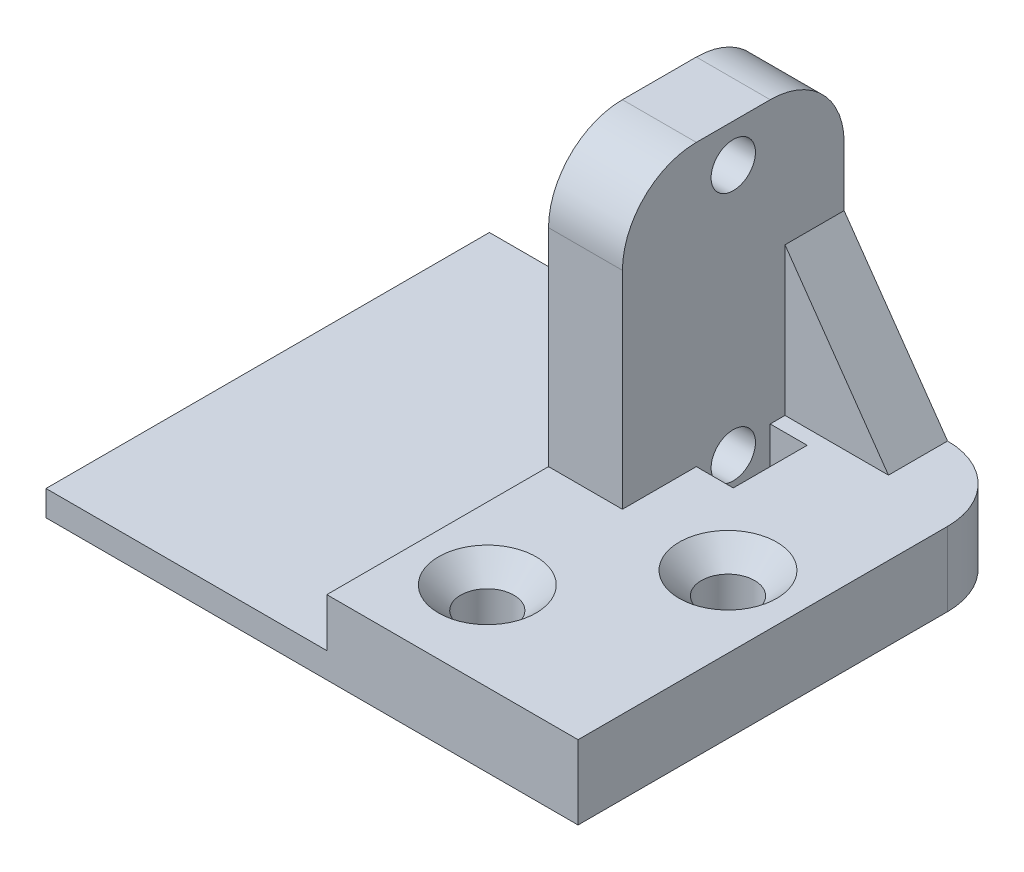
from build123d import *

# Parameters (mm, degrees)
SKETCH_1_W                = 15
SKETCH_1_H                = 24
SKETCH_1_R                = 1.5
EXTRUDE_1_DEPTH           = 5
SKETCH_2_W                = 30
SKETCH_2_H                = 1.720004632
EXTRUDE_2_DEPTH           = 19
EXTRUDE_5_DEPTH           = 5
SKETCH_7_W                = 2.5
SKETCH_7_H                = 5
CUT_EXTRUDE_1_DEPTH       = 3
FILLET_1_R                = 5
HOLE_WIZARD_1_D           = 3.6
HOLE_WIZARD_1_CSINK_D     = 6.6
HOLE_WIZARD_1_CSINK_ANGLE = 90
RIB_1_REACH               = 44.86
SKETCH_10_WALL_W          = 99.927031582
SKETCH_10_WALL_H          = 4


with BuildPart() as part:
    # 草图1 → 凸台-拉伸1 (new body)
    with BuildSketch(Plane(origin=(0, 0, 0), x_dir=(0, 0, -1), z_dir=(1, 0, 0))):
        with Locations((0, 12)):
            Rectangle(SKETCH_1_W, SKETCH_1_H)
        with Locations((0, 4.420004632)):
            Circle(SKETCH_1_R, mode=Mode.SUBTRACT)
        with Locations((0, 21.420004632)):
            Circle(SKETCH_1_R, mode=Mode.SUBTRACT)
    extrude(amount=EXTRUDE_1_DEPTH)

    # 草图2 → 凸台-拉伸2 (add)
    with BuildSketch(Plane.ZY):
        with Locations((7.5, 0.860002316)):
            Rectangle(SKETCH_2_W, SKETCH_2_H)
    extrude(amount=EXTRUDE_2_DEPTH)

    # 草图4 → 凸台-拉伸5 (add)
    with BuildSketch(Plane(origin=(0, 0, 0), x_dir=(1, 0, 0), z_dir=(0, 1, 0))):
        Polygon((5, 7.5), (17, 7.5), (17, -22.5), (0, -22.5), (0, -7.5), (5, -7.5), align=None)
    extrude(amount=EXTRUDE_5_DEPTH)

    # 草图7 → 切除-拉伸1 (cut)
    with BuildSketch(Plane(origin=(0, 5, 0), x_dir=(1, 0, 0), z_dir=(0, 1, 0))):
        with Locations((6.25, 0)):
            Rectangle(SKETCH_7_W, SKETCH_7_H)
    extrude(amount=-CUT_EXTRUDE_1_DEPTH, mode=Mode.SUBTRACT)

    # 圆角1
    fillet_1_edges = [part.edges().sort_by_distance(p)[0] for p in [
        (17, 2.5, -7.5),
        (2.5, 24, 7.5),
        (2.5, 24, -7.5),
    ]]
    fillet(fillet_1_edges, radius=FILLET_1_R)

    # 打孔尺寸(%根据十字)槽半沉头木螺钉的类型1 (through all)
    with Locations(Plane(origin=(0, 5, 0), x_dir=(1, 0, 0), z_dir=(0, 1, 0))):
        with Locations((4.857142857, -16.5), (12.142857143, -7.5)):
            CounterSinkHole(HOLE_WIZARD_1_D / 2, HOLE_WIZARD_1_CSINK_D / 2, counter_sink_angle=HOLE_WIZARD_1_CSINK_ANGLE)

    # 草图10 wall → 筋1 (add, up to next)
    with BuildSketch(Plane(origin=(8.5, 10, -7.5), x_dir=(-0.573462344363, 0.819231920519, 0), z_dir=(0.819231920519, 0.573462344363, 0)), mode=Mode.PRIVATE) as rib_1_sk1:
        with Locations((0, 2)):
            Rectangle(SKETCH_10_WALL_W, SKETCH_10_WALL_H)
    rib_1_tool1 = extrude(rib_1_sk1.sketch, amount=-RIB_1_REACH, mode=Mode.PRIVATE) - part.part
    add(rib_1_tool1.solids().sort_by_distance((8.5, 10, -7.5))[0])


solid = part.part
